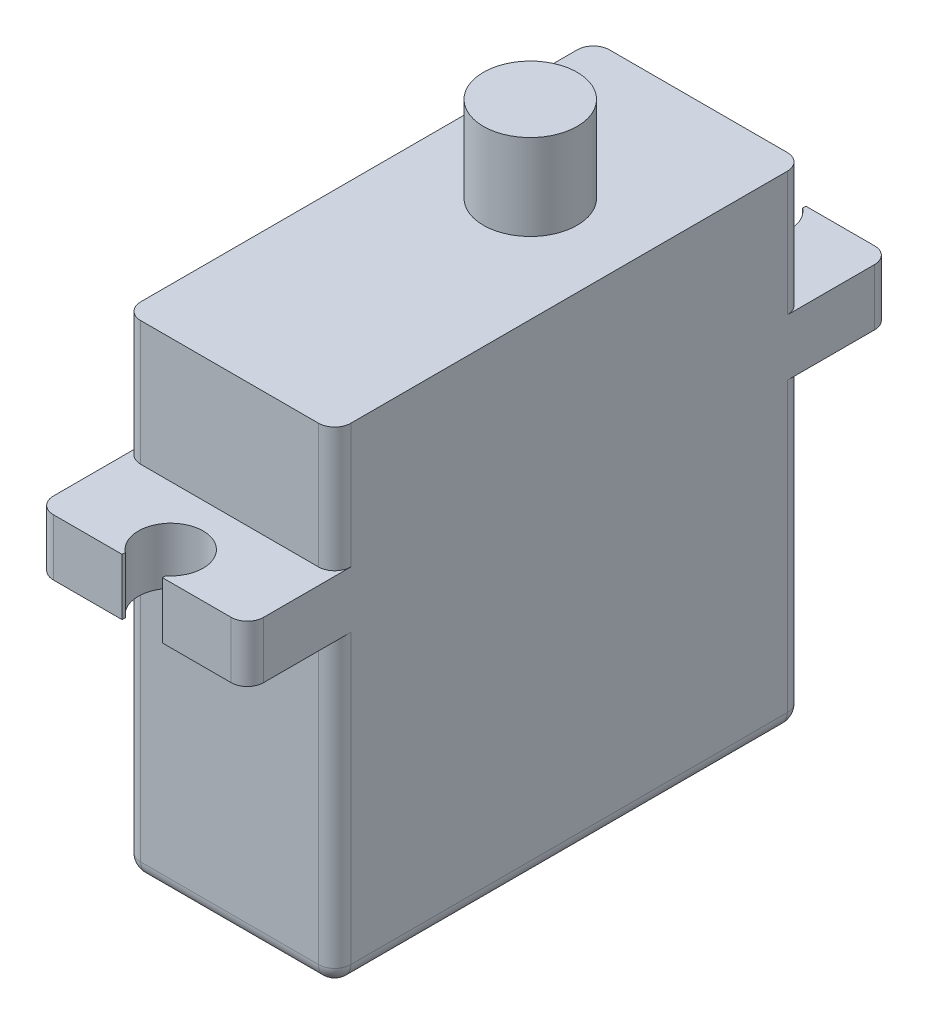
from build123d import *

# Parameters (mm, degrees)
SKETCH2_W           = 29
SKETCH2_H           = 30
SKETCH2_W_2         = 5.4
SKETCH2_H_2         = 3.5
SKETCH2_W_3         = 5.8
SKETCH2_H_3         = 5.3
BOSS_EXTRUDE1_DEPTH = 13
CUT_EXTRUDE1_DEPTH  = 5.3
CUT_EXTRUDE2_DEPTH  = 31
FILLET1_R           = 1


with BuildPart() as part:
    # Sketch2 → Boss-Extrude1 (new body)
    with BuildSketch(Plane(origin=(0, 0, 0), x_dir=(0, 0, -1), z_dir=(1, 0, 0))):
        Rectangle(SKETCH2_W, SKETCH2_H)
        with Locations((-17.2, 5.55)):
            Rectangle(SKETCH2_W_2, SKETCH2_H_2)
        with Locations((4.1, 17.65)):
            Rectangle(SKETCH2_W_3, SKETCH2_H_3)
        with Locations((17.2, 5.55)):
            Rectangle(SKETCH2_W_2, SKETCH2_H_2)
    extrude(amount=BOSS_EXTRUDE1_DEPTH)

    # Sketch3 → Cut-Extrude1 (cut)
    with BuildSketch(Plane(origin=(0, 15, 0), x_dir=(1, 0, 0), z_dir=(0, 1, 0))):
        with BuildLine():
            Line((6.5, 1.2), (9.4, 1.2))
            Line((9.4, 1.2), (9.4, 4.1))
            ThreePointArc((9.4, 4.1), (8.550609665, 2.049390335), (6.5, 1.2))
        make_face()
        with BuildLine():
            ThreePointArc((6.5, 7), (8.550609665, 6.150609665), (9.4, 4.1))
            Line((9.4, 4.1), (9.4, 7))
            Line((9.4, 7), (6.5, 7))
        make_face()
        with BuildLine():
            ThreePointArc((3.6, 4.1), (4.449390335, 6.150609665), (6.5, 7))
            Line((6.5, 7), (3.6, 7))
            Line((3.6, 7), (3.6, 4.1))
        make_face()
        with BuildLine():
            Line((3.6, 1.2), (6.5, 1.2))
            ThreePointArc((6.5, 1.2), (4.449390335, 2.049390335), (3.6, 4.1))
            Line((3.6, 4.1), (3.6, 1.2))
        make_face()
        Polygon((0, 1.2), (3.6, 1.2), (3.6, 4.1), (3.6, 7), (0, 7), align=None)
        Polygon((9.4, 1.2), (13, 1.2), (13, 7), (9.4, 7), (9.4, 4.1), align=None)
        with BuildLine():
            Line((7.75, 19.7), (7.75, 19.9))
            Line((7.75, 19.9), (5.25, 19.9))
            Line((5.25, 19.9), (5.25, 19.7))
            ThreePointArc((5.25, 19.7), (6.5, 16.1387505), (7.75, 19.7))
        make_face()
        with BuildLine():
            Line((5.25, -19.9), (7.75, -19.9))
            Line((7.75, -19.9), (7.75, -19.7))
            ThreePointArc((7.75, -19.7), (6.5, -16.1387505), (5.25, -19.7))
            Line((5.25, -19.7), (5.25, -19.9))
        make_face()
    extrude(amount=CUT_EXTRUDE1_DEPTH, mode=Mode.SUBTRACT)

    # Sketch3_4 → Cut-Extrude2 (cut, through all)
    with BuildSketch(Plane(origin=(0, 15, 0), x_dir=(1, 0, 0), z_dir=(0, 1, 0))):
        with BuildLine():
            Line((7.75, 19.7), (7.75, 19.9))
            Line((7.75, 19.9), (5.25, 19.9))
            Line((5.25, 19.9), (5.25, 19.7))
            ThreePointArc((5.25, 19.7), (6.5, 16.1387505), (7.75, 19.7))
        make_face()
        with BuildLine():
            Line((5.25, -19.9), (7.75, -19.9))
            Line((7.75, -19.9), (7.75, -19.7))
            ThreePointArc((7.75, -19.7), (6.5, -16.1387505), (5.25, -19.7))
            Line((5.25, -19.7), (5.25, -19.9))
        make_face()
    extrude(amount=-CUT_EXTRUDE2_DEPTH, mode=Mode.SUBTRACT)

    # Fillet1
    fillet1_edges = [part.edges().sort_by_distance(p)[0] for p in [
        (0, 5.55, -19.9),
        (0, -5.6, -14.5),
        (0, -15, 0),
        (0, -5.6, 14.5),
        (0, 5.55, 19.9),
        (0, 11.15, 14.5),
        (0, 11.15, -14.5),
        (6.5, -15, -14.5),
        (6.5, -15, 14.5),
        (13, 11.15, 14.5),
        (13, 5.55, 19.9),
        (13, 11.15, -14.5),
        (13, -5.6, 14.5),
        (13, -15, 0),
        (13, -5.6, -14.5),
        (13, 5.55, -19.9),
    ]]
    fillet(fillet1_edges, radius=FILLET1_R)


solid = part.part
